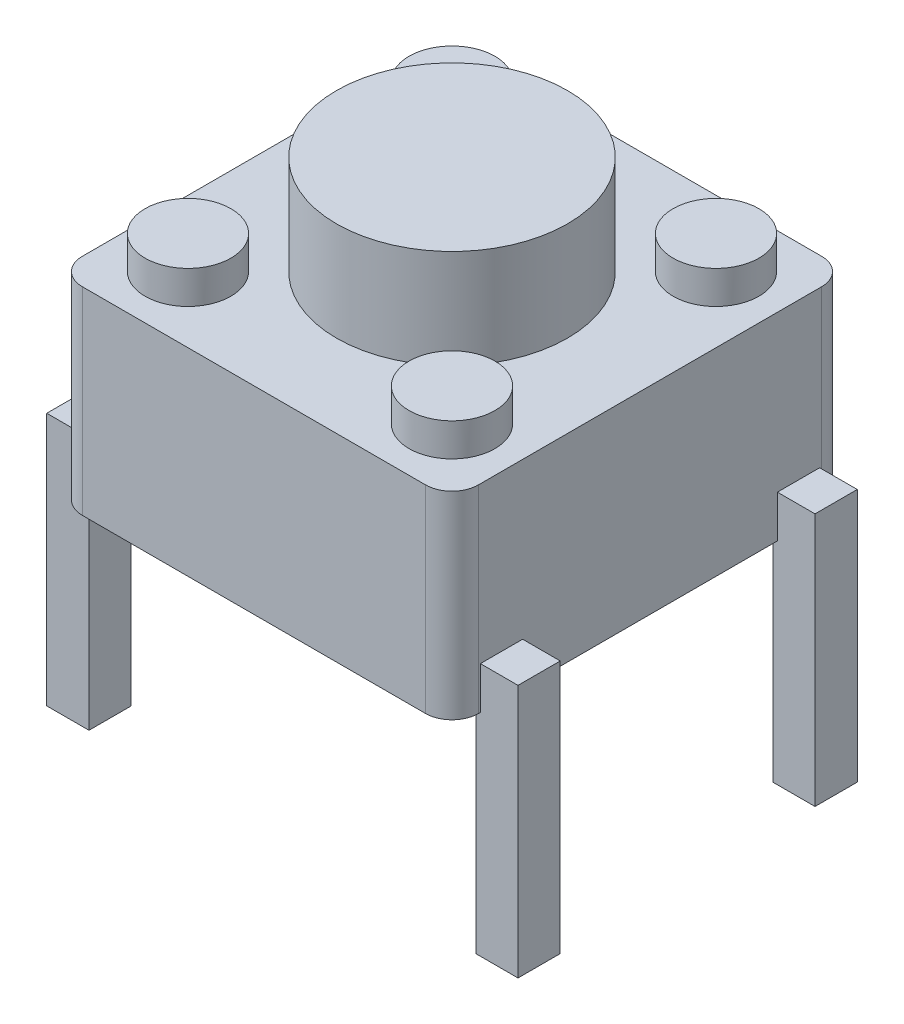
from build123d import *

# Parameters (mm, degrees)
SKETCH1_W           = 6
SKETCH1_H           = 6
BOSS_EXTRUDE1_DEPTH = 3
SKETCH2_R           = 1.75
BOSS_EXTRUDE2_DEPTH = 1.5
SKETCH3_R           = 0.65
BOSS_EXTRUDE3_DEPTH = 0.5
SKETCH4_W           = 0.64
SKETCH4_H           = 0.64
BOSS_EXTRUDE4_DEPTH = 3.2
FILLET1_R           = 0.4
SKETCH6_W           = 0.64
SKETCH6_H           = 0.64
BOSS_EXTRUDE6_DEPTH = 7.14


with BuildPart() as part:
    # Sketch1 → Boss-Extrude1 (new body)
    with BuildSketch(Plane(origin=(0, 0, 0), x_dir=(1, 0, 0), z_dir=(0, 1, 0))):
        Rectangle(SKETCH1_W, SKETCH1_H)
    extrude(amount=BOSS_EXTRUDE1_DEPTH)

    # Sketch2 → Boss-Extrude2 (add)
    with BuildSketch(Plane(origin=(0, 3, 0), x_dir=(1, 0, 0), z_dir=(0, 1, 0))):
        Circle(SKETCH2_R)
    extrude(amount=BOSS_EXTRUDE2_DEPTH)

    # Sketch3 → Boss-Extrude3 (add)
    with BuildSketch(Plane(origin=(0, 3, 0), x_dir=(1, 0, 0), z_dir=(0, 1, 0))):
        with Locations((-2, 2)):
            Circle(SKETCH3_R)
        with Locations((-2, -2)):
            Circle(SKETCH3_R)
        with Locations((2, -2)):
            Circle(SKETCH3_R)
        with Locations((2, 2)):
            Circle(SKETCH3_R)
    extrude(amount=BOSS_EXTRUDE3_DEPTH)

    # Sketch4 → Boss-Extrude4 (add)
    with BuildSketch(Plane.XZ):
        with Locations((-3.25, 2.25)):
            Rectangle(SKETCH4_W, SKETCH4_H)
        with Locations((3.25, 2.25)):
            Rectangle(SKETCH4_W, SKETCH4_H)
        with Locations((3.25, -2.25)):
            Rectangle(SKETCH4_W, SKETCH4_H)
        with Locations((-3.25, -2.25)):
            Rectangle(SKETCH4_W, SKETCH4_H)
    extrude(amount=BOSS_EXTRUDE4_DEPTH)

    # Fillet1
    fillet1_edges = [part.edges().sort_by_distance(p)[0] for p in [
        (3, 1.5, 3),
        (-3, 1.5, 3),
        (-3, 1.5, -3),
        (3, 1.5, -3),
    ]]
    fillet(fillet1_edges, radius=FILLET1_R)

    # Sketch6 → Boss-Extrude6 (add)
    with BuildSketch(Plane.ZY.offset(3.57)):
        with Locations((-2.25, 0.32)):
            Rectangle(SKETCH6_W, SKETCH6_H)
        with Locations((2.25, 0.32)):
            Rectangle(SKETCH6_W, SKETCH6_H)
    extrude(amount=-BOSS_EXTRUDE6_DEPTH)


solid = part.part
